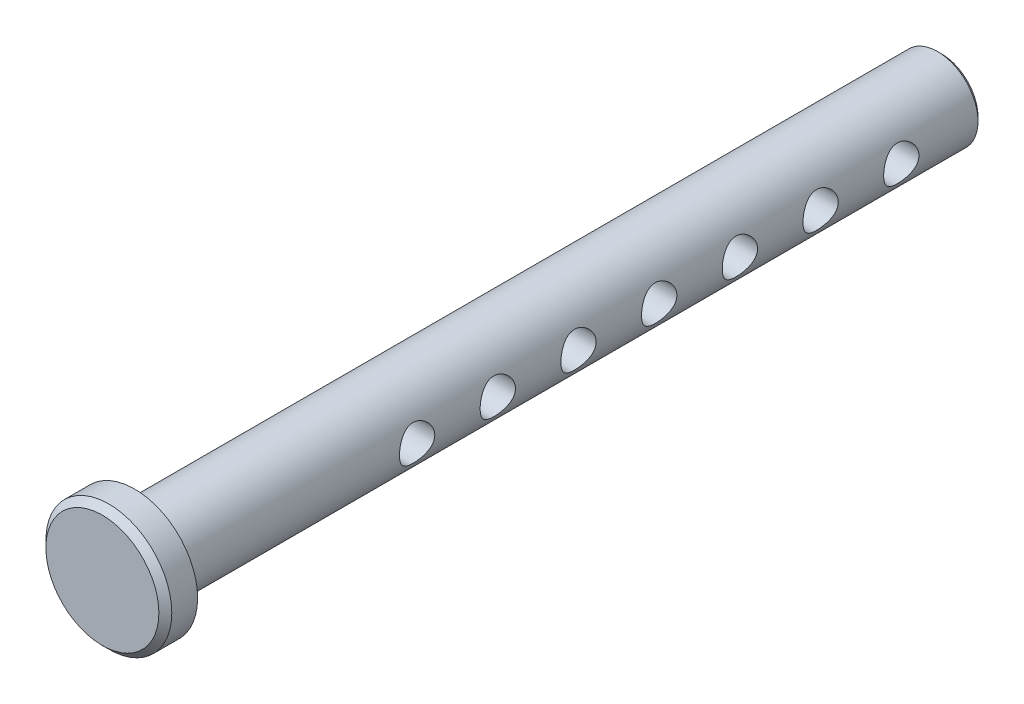
from build123d import *

# Parameters (mm, degrees)
SKETCH1_R       = 3.175
EXTRUDE1_DEPTH  = 31.75
SKETCH2_R       = 4.953
EXTRUDE2_DEPTH  = 2.54
CHAMFER1_SIZE   = 0.508
SKETCH3_R       = 1.3890625
EXTRUDE3_DEPTH  = 5.953
LPATTERN1_COUNT = 7
LPATTERN1_PITCH = 6.35
CHAMFER2_SIZE   = 0.3175


with BuildPart() as part:
    # Sketch1 → Extrude1 (new body, symmetric)
    with BuildSketch(Plane.XY):
        Circle(SKETCH1_R)
    extrude(amount=EXTRUDE1_DEPTH, both=True)

    # Sketch2 → Extrude2 (add)
    with BuildSketch(Plane.XY.offset(31.75)):
        Circle(SKETCH2_R)
    extrude(amount=EXTRUDE2_DEPTH)

    # Chamfer1
    chamfer1_edges = [part.edges().sort_by_distance(p)[0] for p in [
        (-4.953, 0, 34.29),
    ]]
    chamfer(chamfer1_edges, length=CHAMFER1_SIZE)

    # Sketch3 → Extrude3 (cut, symmetric)
    with BuildSketch(Plane(origin=(0, 0, 0), x_dir=(0, 0, -1), z_dir=(1, 0, 0))):
        with Locations((25.4, 0)):
            Circle(SKETCH3_R)
    extrude3 = extrude(amount=EXTRUDE3_DEPTH, both=True, mode=Mode.SUBTRACT)

    # LPattern1: Extrude3 ×7
    with Locations(*[(0, 0, i * LPATTERN1_PITCH) for i in range(1, LPATTERN1_COUNT)]):
        add(extrude3, mode=Mode.SUBTRACT)

    # Chamfer2
    chamfer2_edges = [part.edges().sort_by_distance(p)[0] for p in [
        (-3.175, 0, -31.75),
    ]]
    chamfer(chamfer2_edges, length=CHAMFER2_SIZE)


solid = part.part
